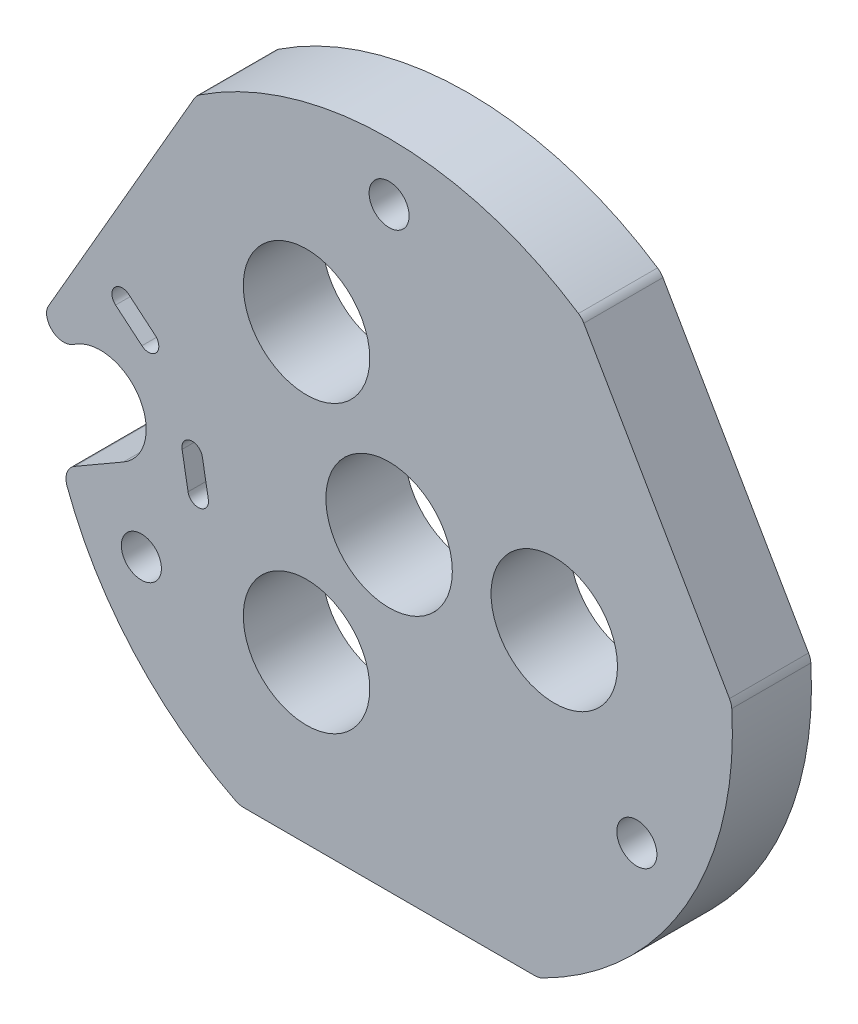
from build123d import *

# Parameters (mm, degrees)
SKETCH1_R           = 5.525
SKETCH1_R_2         = 1.75
BOSS_EXTRUDE1_DEPTH = 6.91


with BuildPart() as part:
    # Sketch1 → Boss-Extrude1 (new body)
    with BuildSketch(Plane.XY):
        with BuildLine():
            Line((27.759212348, 19.618292738), (53.215056471, 19.618292738))
            ThreePointArc((53.215056471, 19.618292738), (53.559180072, 19.658299948), (53.884947106, 19.776187475))
            ThreePointArc((53.884947106, 19.776187475), (66.467896523, 31.618292738), (70.431985807, 48.436499219))
            ThreePointArc((70.431985807, 48.436499219), (70.371195883, 48.77756551), (70.233781342, 49.095588895))
            Line((70.233781342, 49.095588895), (57.505859281, 71.14099658))
            ThreePointArc((57.505859281, 71.14099658), (57.299150221, 71.419012756), (57.03417311, 71.642191519))
            ThreePointArc((57.03417311, 71.642191519), (40.48713441, 76.618292738), (23.940095709, 71.642191519))
            ThreePointArc((23.940095709, 71.642191519), (23.675118599, 71.419012756), (23.468409538, 71.14099658))
            Line((23.468409538, 71.14099658), (10.732258497, 49.081335884))
            ThreePointArc((10.732258497, 49.081335884), (10.618509348, 48.835351928), (10.550877955, 48.572915326))
            ThreePointArc((10.550877955, 48.572915326), (11.255747963, 47.20128209), (12.797690777, 47.176146091))
            Line((12.797690777, 47.176146091), (13.260683436, 47.443455028))
            ThreePointArc((13.260683436, 47.443455028), (18.724785051, 45.979353412), (17.260683436, 40.515251797))
            Line((17.260683436, 40.515251797), (12.998198083, 38.054304731))
            ThreePointArc((12.998198083, 38.054304731), (12.337555741, 37.265255041), (12.340885644, 36.236159988))
            ThreePointArc((12.340885644, 36.236159988), (18.144128021, 26.598550843), (27.089321713, 19.776187475))
            ThreePointArc((27.089321713, 19.776187475), (27.415088747, 19.658299948), (27.759212348, 19.618292738))
        make_face()
        with Locations((33.270256045, 34.118292738)):
            Circle(SKETCH1_R, mode=Mode.SUBTRACT)
        with Locations((54.920891139, 46.618292738)):
            Circle(SKETCH1_R, mode=Mode.SUBTRACT)
        with Locations((33.270256045, 59.118292738)):
            Circle(SKETCH1_R, mode=Mode.SUBTRACT)
        with Locations((40.48713441, 46.618292738)):
            Circle(SKETCH1_R, mode=Mode.SUBTRACT)
        with Locations((18.836499315, 34.118292738)):
            Circle(SKETCH1_R_2, mode=Mode.SUBTRACT)
        with Locations((62.137769504, 34.118292738)):
            Circle(SKETCH1_R_2, mode=Mode.SUBTRACT)
        with Locations((40.48713441, 71.618292738)):
            Circle(SKETCH1_R_2, mode=Mode.SUBTRACT)
        with BuildLine():
            Line((24.689235101, 41.401001388), (24.168290568, 44.355424648))
            ThreePointArc((24.168290568, 44.355424648), (23.12568023, 45.085468265), (22.395636613, 44.042857928))
            Line((22.395636613, 44.042857928), (22.916581146, 41.088434669))
            ThreePointArc((22.916581146, 41.088434669), (23.959191483, 40.358391051), (24.689235101, 41.401001388))
        make_face(mode=Mode.SUBTRACT)
        with BuildLine():
            Line((20.040174245, 51.505531858), (17.742040916, 53.433894687))
            ThreePointArc((17.742040916, 53.433894687), (16.474092068, 53.322963537), (16.585023219, 52.055014689))
            Line((16.585023219, 52.055014689), (18.883156548, 50.12665186))
            ThreePointArc((18.883156548, 50.12665186), (20.151105395, 50.237583011), (20.040174245, 51.505531858))
        make_face(mode=Mode.SUBTRACT)
    extrude(amount=BOSS_EXTRUDE1_DEPTH)


solid = part.part
